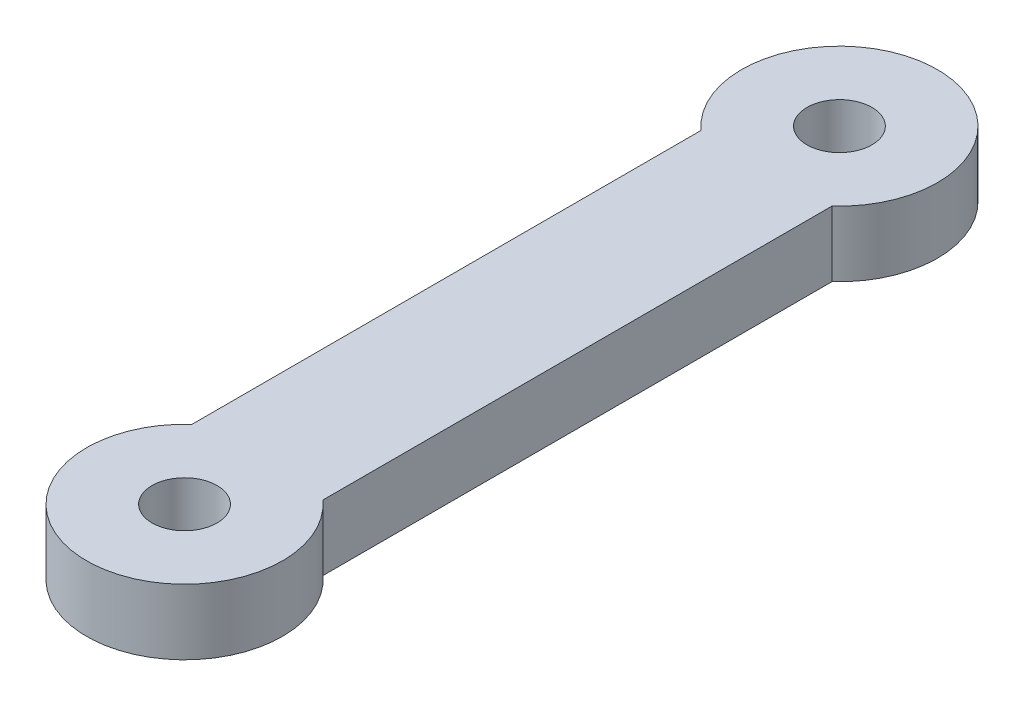
from build123d import *

# Parameters (mm, degrees)
PROFILE_SKETCH_R    = 1.575
BOSS_EXTRUDE1_DEPTH = 3.175


with BuildPart() as part:
    # Profile Sketch → Boss-Extrude1 (new body)
    with BuildSketch(Plane(origin=(0, 0, 0), x_dir=(1, 0, 0), z_dir=(0, 1, 0))):
        with BuildLine():
            Line((3.175, -28.217030286), (3.175, -3.532969714))
            ThreePointArc((3.175, -3.532969714), (0, 4.75), (-3.175, -3.532969714))
            Line((-3.175, -3.532969714), (-3.175, -28.217030286))
            ThreePointArc((-3.175, -28.217030286), (0, -36.5), (3.175, -28.217030286))
        make_face()
        Circle(PROFILE_SKETCH_R, mode=Mode.SUBTRACT)
        with Locations((0, -31.75)):
            Circle(PROFILE_SKETCH_R, mode=Mode.SUBTRACT)
    extrude(amount=BOSS_EXTRUDE1_DEPTH)


solid = part.part
